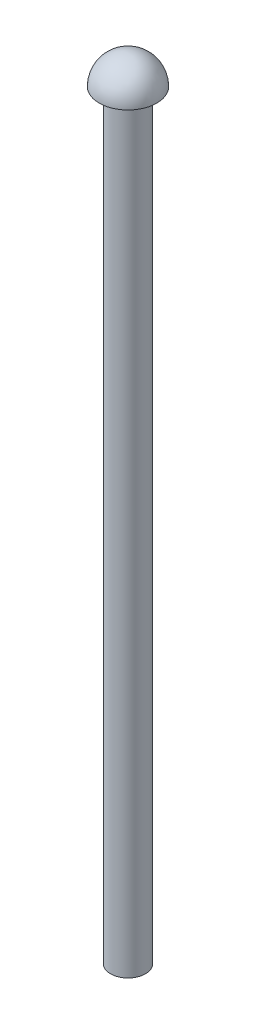
from build123d import *

# Parameters (mm, degrees)
SKETCH4_R           = 0.875
BOSS_EXTRUDE1_DEPTH = 38


with BuildPart() as part:
    # Sketch1 → Revolve-Thin4 (revolve)
    with BuildSketch(Plane(origin=(0, 0, 0), x_dir=(0, 0, -1), z_dir=(1, 0, 0))):
        with BuildLine():
            Line((0, 0), (1.44, 0))
            ThreePointArc((1.44, 0), (1.018233765, 1.018233765), (0, 1.44))
            Line((0, 1.44), (0, 1.34))
            ThreePointArc((0, 1.34), (0.911482309, 0.982242333), (1.336263447, 0.1))
            Line((1.336263447, 0.1), (0, 0.1))
            Line((0, 0.1), (0, 0))
        make_face()
    revolve(axis=Axis((0, -0.072, 0), (0, 1, 0)))

    # Sketch4 → Boss-Extrude1 (add)
    with BuildSketch(Plane.XZ):
        Circle(SKETCH4_R)
    extrude(amount=BOSS_EXTRUDE1_DEPTH)


solid = part.part
